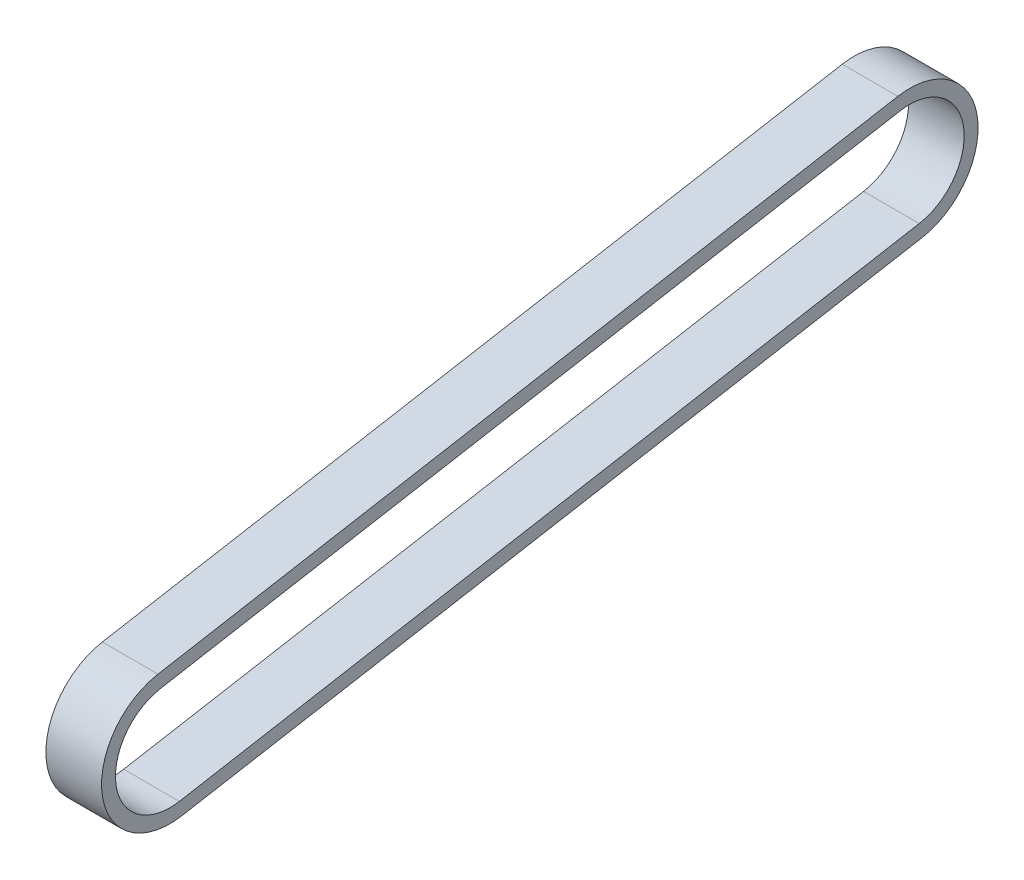
from build123d import *

# Parameters (mm, degrees)
BOSS_EXTRUDE1_DEPTH = 3


with BuildPart() as part:
    # Sketch2 → Boss-Extrude1 (new body, symmetric)
    with BuildSketch(Plane.ZY.offset(34.45)):
        with BuildLine():
            Line((-38.720907523, 77.254093909), (41.048520471, 63.188591518))
            ThreePointArc((41.048520471, 63.188591518), (47.023521903, 54.655405132), (38.490335517, 48.6804037))
            Line((38.490335517, 48.6804037), (-41.279092477, 62.745906091))
            ThreePointArc((-41.279092477, 62.745906091), (-47.254093909, 71.279092477), (-38.720907523, 77.254093909))
        make_face()
        with BuildLine():
            Line((-38.98137979, 75.776882279), (40.788048204, 61.711379888))
            ThreePointArc((40.788048204, 61.711379888), (45.546310273, 54.915877399), (38.750807784, 50.15761533))
            Line((38.750807784, 50.15761533), (-41.01862021, 64.223117721))
            ThreePointArc((-41.01862021, 64.223117721), (-45.776882279, 71.01862021), (-38.98137979, 75.776882279))
        make_face(mode=Mode.SUBTRACT)
    extrude(amount=BOSS_EXTRUDE1_DEPTH, both=True)


solid = part.part
